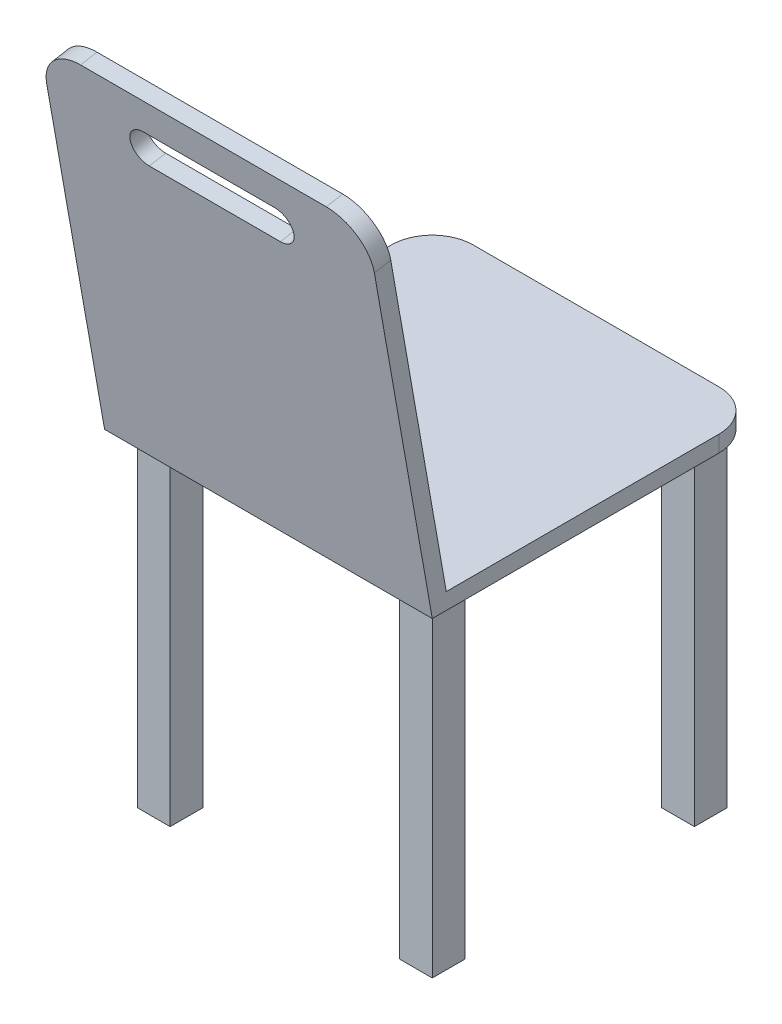
from build123d import *

# Parameters (mm, degrees)
BOSS_EXTRUDE1_DEPTH = 400
SKETCH2_W           = 40
SKETCH2_H           = 40
BOSS_EXTRUDE2_DEPTH = 400
CUT_EXTRUDE2_DEPTH  = 360
FILLET2_R           = 50
FILLET3_R           = 50
FILLET4_R           = 50
FILLET5_R           = 50


with BuildPart() as part:
    # Sketch1 → Boss-Extrude1 (new body)
    with BuildSketch(Plane(origin=(0, 0, 0), x_dir=(0, 0, -1), z_dir=(1, 0, 0))):
        Polygon((0, 0), (-79.347141319, 450), (-59.347141319, 453.526539614), (17.095284468, 20), (400, 20), (400, 0), align=None)
    extrude(amount=BOSS_EXTRUDE1_DEPTH)

    # Sketch2 → Boss-Extrude2 (add)
    with BuildSketch(Plane(origin=(0, 0, 0), x_dir=(1, 0, 0), z_dir=(0, 1, 0))):
        with Locations((40, 40)):
            Rectangle(SKETCH2_W, SKETCH2_H)
        with Locations((360, 40)):
            Rectangle(SKETCH2_W, SKETCH2_H)
        with Locations((40, 360)):
            Rectangle(SKETCH2_W, SKETCH2_H)
        with Locations((360, 360)):
            Rectangle(SKETCH2_W, SKETCH2_H)
    extrude(amount=-BOSS_EXTRUDE2_DEPTH)

    # Sketch3 → Cut-Extrude2 (cut)
    with BuildSketch(Plane(origin=(0, 232.127585669, 20.308532238), x_dir=(1, 0, 0), z_dir=(0, 0.173648178, -0.984807753))):
        with BuildLine():
            Line((280, -144.814389679), (120, -144.814389679))
            ThreePointArc((120, -144.814389679), (100, -164.814389679), (120, -184.814389679))
            Line((120, -184.814389679), (280, -184.814389679))
            ThreePointArc((280, -184.814389679), (300, -164.814389679), (280, -144.814389679))
        make_face()
    extrude(amount=-CUT_EXTRUDE2_DEPTH, mode=Mode.SUBTRACT)

    # Fillet2
    fillet2_edges = [part.edges().sort_by_distance(p)[0] for p in [
        (400, 451.763269807, 69.347141319),
    ]]
    fillet(fillet2_edges, radius=FILLET2_R)

    # Fillet3
    fillet3_edges = [part.edges().sort_by_distance(p)[0] for p in [
        (0, 451.763269807, 69.347141319),
    ]]
    fillet(fillet3_edges, radius=FILLET3_R)

    # Fillet4
    fillet4_edges = [part.edges().sort_by_distance(p)[0] for p in [
        (0, 10, -400),
    ]]
    fillet(fillet4_edges, radius=FILLET4_R)

    # Fillet5
    fillet5_edges = [part.edges().sort_by_distance(p)[0] for p in [
        (400, 10, -400),
    ]]
    fillet(fillet5_edges, radius=FILLET5_R)


solid = part.part
